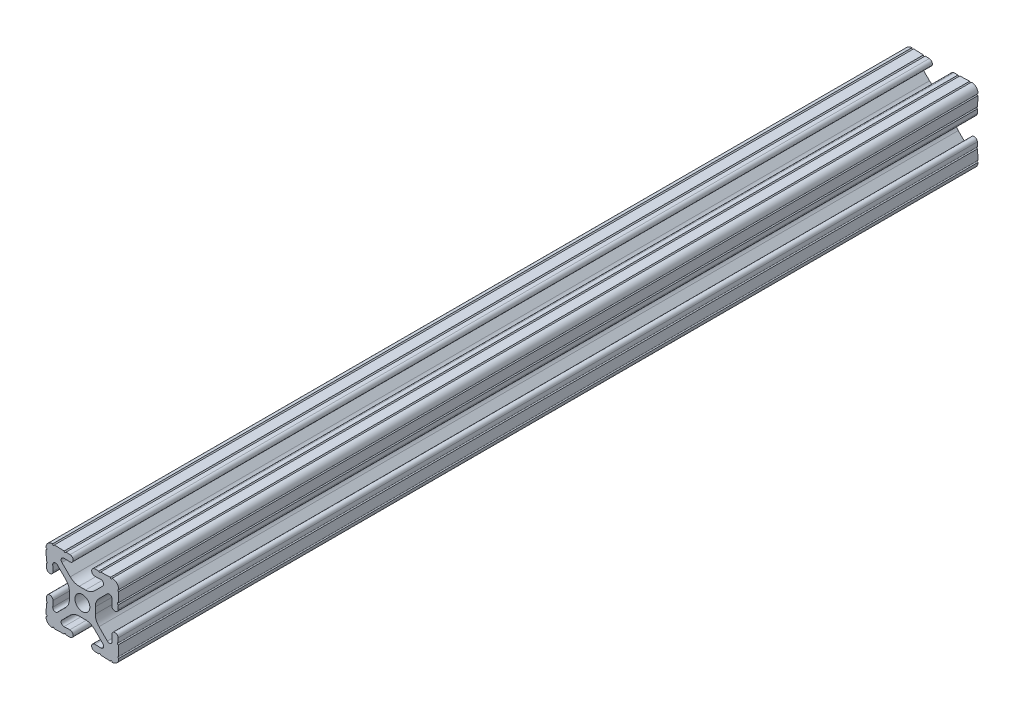
from build123d import *

# Parameters (mm, degrees)
SKETCH3_R               = 2.6035
EXTRUDE1_DEPTH          = 609.6
CUT_EXTRUDE1_DEPTH      = 64
CUT_EXTRUDE1_DEPTH_BACK = 64
SKETCH4_W               = 919.2
SKETCH4_H               = 58.016705437


with BuildPart() as part:
    # Sketch3 → Extrude1 (new, symmetric)
    with BuildSketch(Plane.XY):
        with BuildLine():
            Line((-1.115277175, 4.5085), (1.115277175, 4.5085))
            ThreePointArc((1.115277175, 4.5085), (2.806584872, 4.844922018), (4.240406305, 5.80297087))
            Line((4.240406305, 5.80297087), (7.148423664, 8.710988229))
            ThreePointArc((7.148423664, 8.710988229), (7.349906316, 9.772227925), (6.436353897, 10.348636575))
            Line((6.436353897, 10.348636575), (4.381960454, 10.276895575))
            ThreePointArc((4.381960454, 10.276895575), (3.239173075, 11.342562046), (4.304839546, 12.485349424))
            Line((4.304839546, 12.485349424), (5.728246175, 12.535055879))
            ThreePointArc((5.728246175, 12.535055879), (6.054756855, 12.230579745), (6.35923299, 12.557090424))
            Line((6.35923299, 12.557090424), (9.782092278, 12.676619304))
            ThreePointArc((9.782092278, 12.676619304), (10.108602958, 12.37214317), (10.413079092, 12.69865385))
            ThreePointArc((10.413079092, 12.69865385), (12.052764565, 12.052764565), (12.69865385, 10.413079092))
            ThreePointArc((12.69865385, 10.413079092), (12.37214317, 10.108602958), (12.676619304, 9.782092278))
            Line((12.676619304, 9.782092278), (12.557090424, 6.35923299))
            ThreePointArc((12.557090424, 6.35923299), (12.230579745, 6.054756855), (12.535055879, 5.728246175))
            Line((12.535055879, 5.728246175), (12.485349424, 4.304839546))
            ThreePointArc((12.485349424, 4.304839546), (11.342562046, 3.239173075), (10.276895575, 4.381960454))
            Line((10.276895575, 4.381960454), (10.348636575, 6.436353897))
            ThreePointArc((10.348636575, 6.436353897), (9.772227925, 7.349906316), (8.710988229, 7.148423664))
            Line((8.710988229, 7.148423664), (5.80297087, 4.240406305))
            ThreePointArc((5.80297087, 4.240406305), (4.844922018, 2.806584872), (4.5085, 1.115277175))
            Line((4.5085, 1.115277175), (4.5085, -1.115277175))
            ThreePointArc((4.5085, -1.115277175), (4.844922018, -2.806584872), (5.80297087, -4.240406305))
            Line((5.80297087, -4.240406305), (8.710988229, -7.148423664))
            ThreePointArc((8.710988229, -7.148423664), (9.772227925, -7.349906316), (10.348636575, -6.436353897))
            Line((10.348636575, -6.436353897), (10.276895575, -4.381960454))
            ThreePointArc((10.276895575, -4.381960454), (11.342562046, -3.239173075), (12.485349424, -4.304839546))
            Line((12.485349424, -4.304839546), (12.535055879, -5.728246175))
            ThreePointArc((12.535055879, -5.728246175), (12.230579745, -6.054756855), (12.557090424, -6.35923299))
            Line((12.557090424, -6.35923299), (12.676619304, -9.782092278))
            ThreePointArc((12.676619304, -9.782092278), (12.37214317, -10.108602958), (12.69865385, -10.413079092))
            ThreePointArc((12.69865385, -10.413079092), (12.052764565, -12.052764565), (10.413079092, -12.69865385))
            ThreePointArc((10.413079092, -12.69865385), (10.108602958, -12.37214317), (9.782092278, -12.676619304))
            Line((9.782092278, -12.676619304), (6.35923299, -12.557090424))
            ThreePointArc((6.35923299, -12.557090424), (6.054756855, -12.230579745), (5.728246175, -12.535055879))
            Line((5.728246175, -12.535055879), (4.304839546, -12.485349424))
            ThreePointArc((4.304839546, -12.485349424), (3.239173075, -11.342562046), (4.381960454, -10.276895575))
            Line((4.381960454, -10.276895575), (6.436353897, -10.348636575))
            ThreePointArc((6.436353897, -10.348636575), (7.349906316, -9.772227925), (7.148423664, -8.710988229))
            Line((7.148423664, -8.710988229), (4.240406305, -5.80297087))
            ThreePointArc((4.240406305, -5.80297087), (2.806584872, -4.844922018), (1.115277175, -4.5085))
            Line((1.115277175, -4.5085), (-1.115277175, -4.5085))
            ThreePointArc((-1.115277175, -4.5085), (-2.806584872, -4.844922018), (-4.240406305, -5.80297087))
            Line((-4.240406305, -5.80297087), (-7.148423664, -8.710988229))
            ThreePointArc((-7.148423664, -8.710988229), (-7.349906316, -9.772227925), (-6.436353897, -10.348636575))
            Line((-6.436353897, -10.348636575), (-4.381960454, -10.276895575))
            ThreePointArc((-4.381960454, -10.276895575), (-3.239173075, -11.342562046), (-4.304839546, -12.485349424))
            Line((-4.304839546, -12.485349424), (-5.728246175, -12.535055879))
            ThreePointArc((-5.728246175, -12.535055879), (-6.054756855, -12.230579745), (-6.35923299, -12.557090424))
            Line((-6.35923299, -12.557090424), (-9.782092278, -12.676619304))
            ThreePointArc((-9.782092278, -12.676619304), (-10.108602958, -12.37214317), (-10.413079092, -12.69865385))
            ThreePointArc((-10.413079092, -12.69865385), (-12.052764565, -12.052764565), (-12.69865385, -10.413079092))
            ThreePointArc((-12.69865385, -10.413079092), (-12.37214317, -10.108602958), (-12.676619304, -9.782092278))
            Line((-12.676619304, -9.782092278), (-12.557090424, -6.35923299))
            ThreePointArc((-12.557090424, -6.35923299), (-12.230579745, -6.054756855), (-12.535055879, -5.728246175))
            Line((-12.535055879, -5.728246175), (-12.485349424, -4.304839546))
            ThreePointArc((-12.485349424, -4.304839546), (-11.342562046, -3.239173075), (-10.276895575, -4.381960454))
            Line((-10.276895575, -4.381960454), (-10.348636575, -6.436353897))
            ThreePointArc((-10.348636575, -6.436353897), (-9.772227925, -7.349906316), (-8.710988229, -7.148423664))
            Line((-8.710988229, -7.148423664), (-5.80297087, -4.240406305))
            ThreePointArc((-5.80297087, -4.240406305), (-4.844922018, -2.806584872), (-4.5085, -1.115277175))
            Line((-4.5085, -1.115277175), (-4.5085, 1.115277175))
            ThreePointArc((-4.5085, 1.115277175), (-4.844922018, 2.806584872), (-5.80297087, 4.240406305))
            Line((-5.80297087, 4.240406305), (-8.710988229, 7.148423664))
            ThreePointArc((-8.710988229, 7.148423664), (-9.772227925, 7.349906316), (-10.348636575, 6.436353897))
            Line((-10.348636575, 6.436353897), (-10.276895575, 4.381960454))
            ThreePointArc((-10.276895575, 4.381960454), (-11.342562046, 3.239173075), (-12.485349424, 4.304839546))
            Line((-12.485349424, 4.304839546), (-12.535055879, 5.728246175))
            ThreePointArc((-12.535055879, 5.728246175), (-12.230579745, 6.054756855), (-12.557090424, 6.35923299))
            Line((-12.557090424, 6.35923299), (-12.676619304, 9.782092278))
            ThreePointArc((-12.676619304, 9.782092278), (-12.37214317, 10.108602958), (-12.69865385, 10.413079092))
            ThreePointArc((-12.69865385, 10.413079092), (-12.052764565, 12.052764565), (-10.413079092, 12.69865385))
            ThreePointArc((-10.413079092, 12.69865385), (-10.108602958, 12.37214317), (-9.782092278, 12.676619304))
            Line((-9.782092278, 12.676619304), (-6.35923299, 12.557090424))
            ThreePointArc((-6.35923299, 12.557090424), (-6.054756855, 12.230579745), (-5.728246175, 12.535055879))
            Line((-5.728246175, 12.535055879), (-4.304839546, 12.485349424))
            ThreePointArc((-4.304839546, 12.485349424), (-3.239173075, 11.342562046), (-4.381960454, 10.276895575))
            Line((-4.381960454, 10.276895575), (-6.436353897, 10.348636575))
            ThreePointArc((-6.436353897, 10.348636575), (-7.349906316, 9.772227925), (-7.148423664, 8.710988229))
            Line((-7.148423664, 8.710988229), (-4.240406305, 5.80297087))
            ThreePointArc((-4.240406305, 5.80297087), (-2.806584872, 4.844922018), (-1.115277175, 4.5085))
        make_face()
        Circle(SKETCH3_R, mode=Mode.SUBTRACT)
    extrude(amount=EXTRUDE1_DEPTH, both=True)

    # Sketch4 → Cut-Extrude1 (cut, two sides: drawn at the far end of the back side and taken through both)
    with BuildSketch(Plane(origin=(-12.319997369, -0.430223788, 0), x_dir=(0, 0, 1), z_dir=(-0.9993908270190897, -0.03489949670267645, 0)).offset(-CUT_EXTRUDE1_DEPTH_BACK)):
        with Locations((-150, -0.072150678)):
            Rectangle(SKETCH4_W, SKETCH4_H)
    extrude(amount=CUT_EXTRUDE1_DEPTH + CUT_EXTRUDE1_DEPTH_BACK, mode=Mode.SUBTRACT)


solid = part.part
